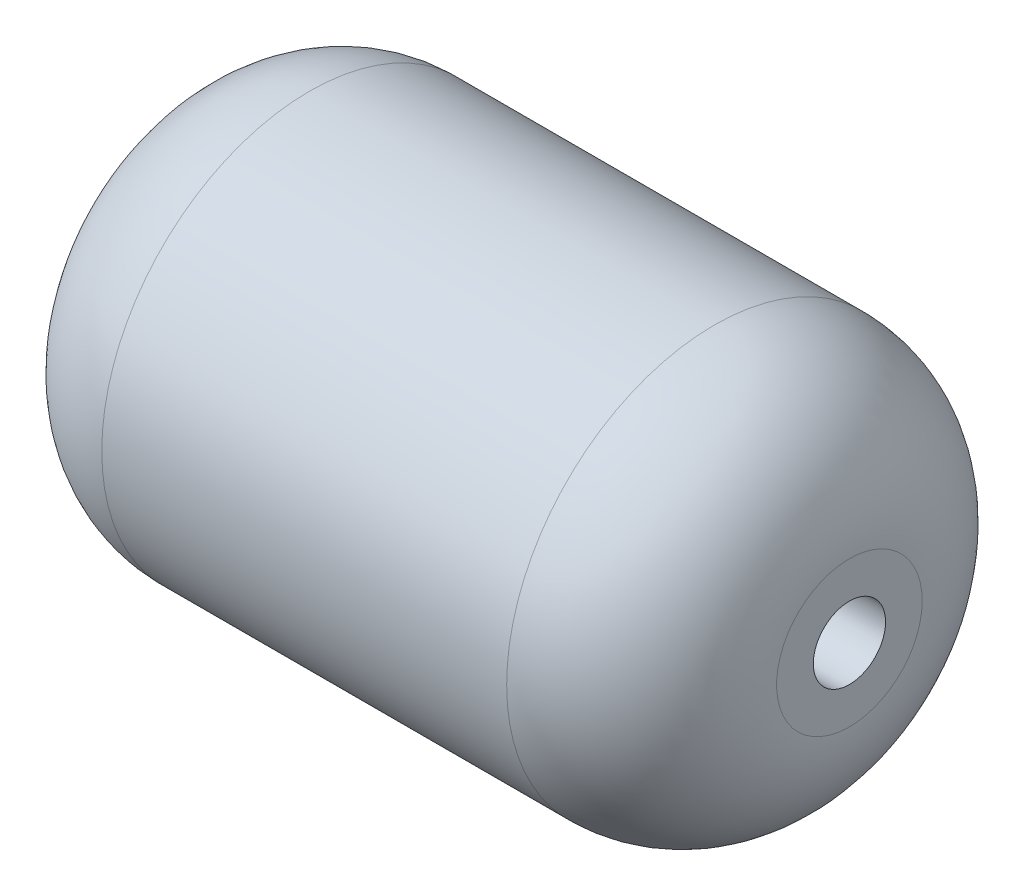
from build123d import *


with BuildPart() as part:
    # Sketch1 → Revolve1 (revolve)
    with BuildSketch(Plane.XY):
        with BuildLine():
            Line((-100, 21.579100204), (-100, 10.707094489))
            Line((-100, 10.707094489), (100, 10.707094489))
            Line((100, 10.707094489), (100, 21.579100204))
            ThreePointArc((100, 21.579100204), (88.284271247, 49.863371451), (60, 61.579100204))
            Line((60, 61.579100204), (-60, 61.579100204))
            ThreePointArc((-60, 61.579100204), (-88.284271247, 49.863371451), (-100, 21.579100204))
        make_face()
        with BuildLine():
            Line((-97.46, 21.579100204), (-97.46, 13.247094489))
            Line((-97.46, 13.247094489), (97.46, 13.247094489))
            Line((97.46, 13.247094489), (97.46, 21.579100204))
            ThreePointArc((97.46, 21.579100204), (86.488220023, 48.067320227), (60, 59.039100204))
            Line((60, 59.039100204), (-60, 59.039100204))
            ThreePointArc((-60, 59.039100204), (-86.488220023, 48.067320227), (-97.46, 21.579100204))
        make_face(mode=Mode.SUBTRACT)
    revolve(axis=Axis((0, 0, 0), (-1, 0, 0)))


solid = part.part
